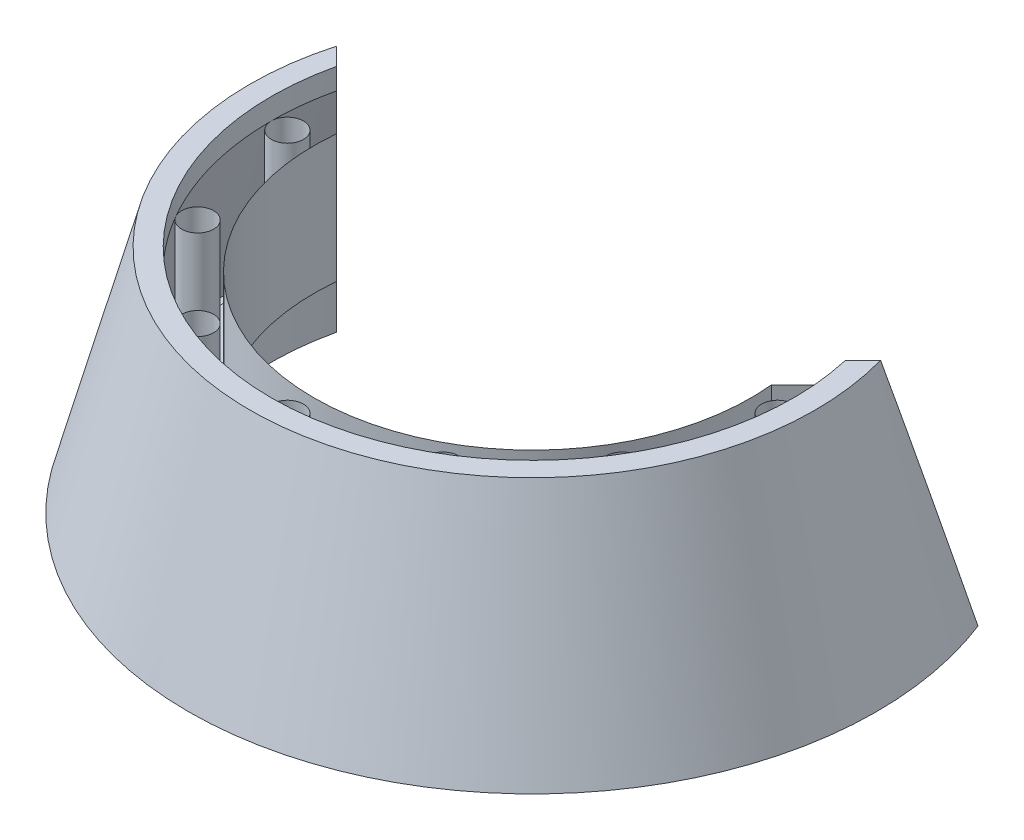
from build123d import *

# Parameters (mm, degrees)
SKETCH2_R               = 4.7625
CUT_EXTRUDE1_DEPTH      = 63.23
CIRPATTERN1_COUNT       = 12
CUT_EXTRUDE2_DEPTH      = 26.4
CUT_EXTRUDE2_DEPTH_BACK = 44.18


with BuildPart() as part:
    # Sketch1 → Revolve1 (revolve)
    with BuildSketch(Plane(origin=(0, 0, 0), x_dir=(0, 0, -1), z_dir=(1, 0, 0))):
        Polygon((65.0875, -19.05), (65.0875, 19.05), (77.7875, 19.05), (77.7875, 25.4), (84.1375, 25.4), (102.513455617, -43.18), (77.7875, -43.18), (77.7875, -25.4), (77.7875, -19.05), align=None)
    revolve(axis=Axis((0, -44.45, 0), (0, 1, 0)))

    # Sketch2 → Cut-Extrude1 (cut, through all)
    with BuildSketch(Plane(origin=(0, 19.05, 0), x_dir=(1, 0, 0), z_dir=(0, 1, 0))):
        with Locations((0, -73.025)):
            Circle(SKETCH2_R)
    cut_extrude1 = extrude(amount=-CUT_EXTRUDE1_DEPTH, mode=Mode.SUBTRACT)

    # CirPattern1: Cut-Extrude1 ×12 about axis
    cirpattern1_axis = Axis((0, 0, 0), (0, 1, 0))
    for i in range(1, CIRPATTERN1_COUNT):
        add(cut_extrude1.rotate(cirpattern1_axis, i * 360 / CIRPATTERN1_COUNT), mode=Mode.SUBTRACT)

    # Sketch3 → Cut-Extrude2 (cut, two sides)
    with BuildSketch(Plane(origin=(0, 0, 0), x_dir=(1, 0, 0), z_dir=(0, 1, 0))) as cut_extrude2_sk:
        with BuildLine():
            Line((0, -58.371664787), (95.538612884, 37.166948097))
            ThreePointArc((95.538612884, 37.166948097), (0, 102.513455617), (-95.538612884, 37.166948097))
            Line((-95.538612884, 37.166948097), (0, -58.371664787))
        make_face()
    extrude(amount=CUT_EXTRUDE2_DEPTH, mode=Mode.SUBTRACT)
    extrude(cut_extrude2_sk.sketch, amount=-CUT_EXTRUDE2_DEPTH_BACK, mode=Mode.SUBTRACT)


solid = part.part
